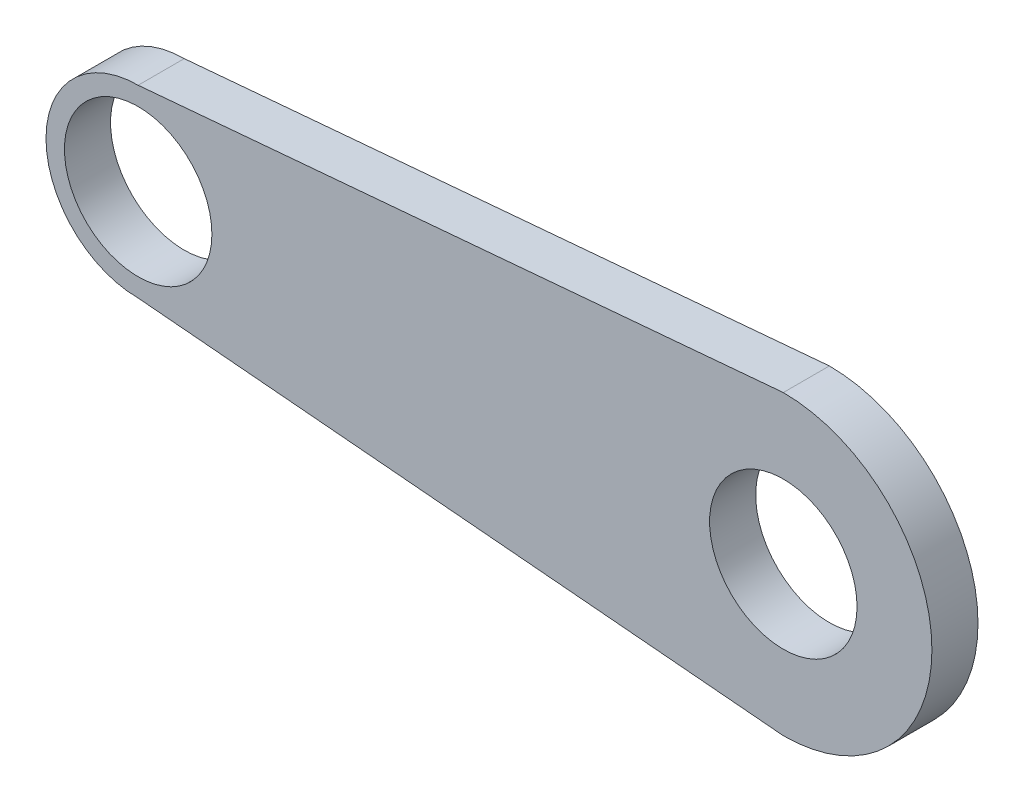
from build123d import *

# Parameters (mm, degrees)
SKETCH1_R           = 20.32
BOSS_EXTRUDE1_DEPTH = 12.7


with BuildPart() as part:
    # Sketch1 → Boss-Extrude1 (new body)
    with BuildSketch(Plane.XY):
        with BuildLine():
            Line((37.409275597, 7.872494736), (-133.278879175, -7.060783805))
            ThreePointArc((-133.278879175, -7.060783805), (-158.678879175, -32.460783805), (-133.278879175, -57.860783805))
            Line((-133.278879175, -57.860783805), (37.409275597, -72.794062346))
            Line((37.409275597, -72.794062346), (44.521120825, -73.41626818))
            ThreePointArc((44.521120825, -73.41626818), (85.476605199, -32.460783805), (44.521120825, 8.49470057))
            Line((44.521120825, 8.49470057), (37.409275597, 7.872494736))
        make_face()
        with Locations((-133.278879175, -32.460783805)):
            Circle(SKETCH1_R, mode=Mode.SUBTRACT)
        with Locations((44.521120825, -32.460783805)):
            Circle(SKETCH1_R, mode=Mode.SUBTRACT)
    extrude(amount=BOSS_EXTRUDE1_DEPTH)


solid = part.part
